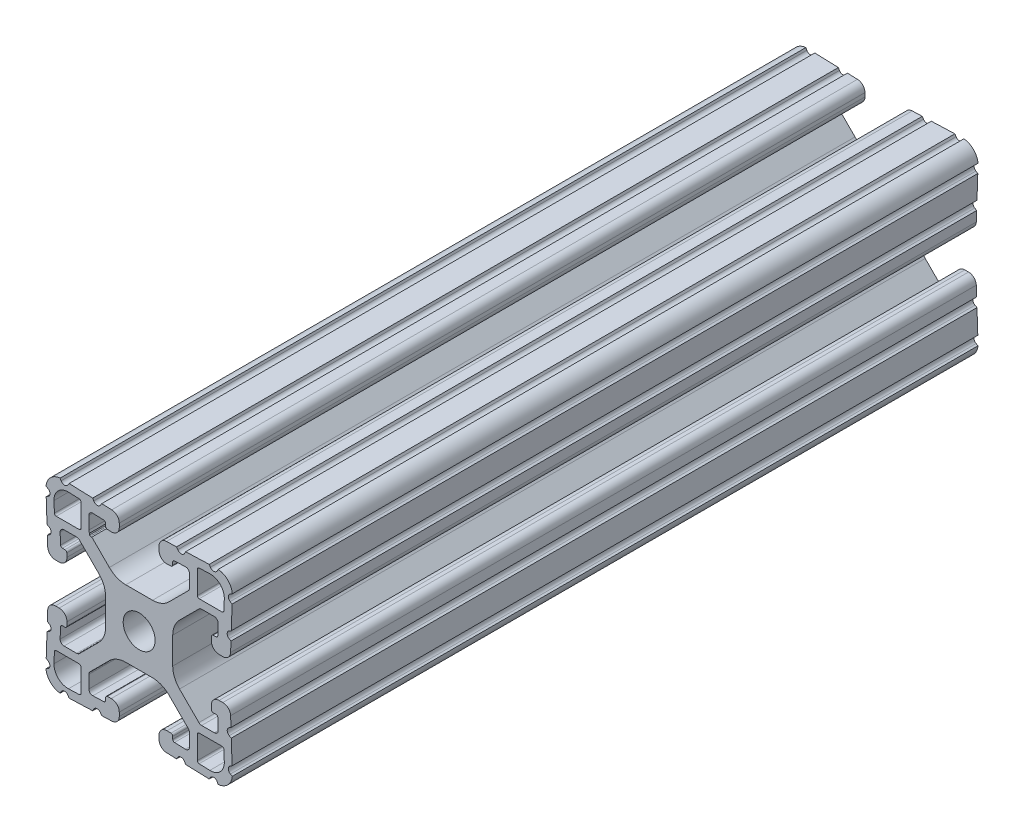
from build123d import *

# Parameters (mm, degrees)
BOSS_EXTRUDE1_DEPTH     = 76.2
CUT_EXTRUDE2_DEPTH      = 77.2
CUT_EXTRUDE2_DEPTH_BACK = 77.2
CUT_EXTRUDE1_DEPTH      = 77.2
CUT_EXTRUDE1_DEPTH_BACK = 77.2


with BuildPart() as part:
    # Sketch4 → Boss-Extrude1 (new body, symmetric)
    with BuildSketch(Plane.XY):
        with BuildLine():
            Line((15.764194098, -19.048065876), (5.596097049, -18.692988103))
            ThreePointArc((5.596097049, -18.692988103), (4.509548067, -18.209225328), (4.064, -17.106455165))
            Line((4.064, -17.106455165), (4.064, -16.343990692))
            ThreePointArc((4.064, -16.343990692), (4.548729837, -15.202038759), (5.706902951, -14.757457754))
            Line((5.706902951, -14.757457754), (6.490296708, -14.784814467))
            ThreePointArc((6.490296708, -14.784814467), (6.751068464, -14.900917533), (6.858, -15.165582372))
            Line((6.858, -15.165582372), (6.858, -15.689138401))
            ThreePointArc((6.858, -15.689138401), (6.964931536, -15.95380324), (7.225703292, -16.069906306))
            Line((7.225703292, -16.069906306), (9.465548524, -16.148123425))
            ThreePointArc((9.465548524, -16.148123425), (10.044635082, -15.925832923), (10.287, -15.354856956))
            Line((10.287, -15.354856956), (10.287, -12.771043484))
            ThreePointArc((10.287, -12.771043484), (10.226579379, -12.46728851), (10.054516008, -12.209777477))
            Line((10.054516008, -12.209777477), (6.093922742, -8.249184211))
            ThreePointArc((6.093922742, -8.249184211), (4.552976719, -7.219556996), (2.735306952, -6.858))
            Line((2.735306952, -6.858), (0, -6.858))
            Line((0, -6.858), (0, -3.2639))
            ThreePointArc((0, -3.2639), (2.307925823, -2.307925823), (3.2639, 0))
            Line((3.2639, 0), (6.858, 0))
            Line((6.858, 0), (6.858, -2.735306952))
            ThreePointArc((6.858, -2.735306952), (7.219556996, -4.552976719), (8.249184211, -6.093922742))
            Line((8.249184211, -6.093922742), (12.209777477, -10.054516008))
            ThreePointArc((12.209777477, -10.054516008), (12.46728851, -10.226579379), (12.771043484, -10.287))
            Line((12.771043484, -10.287), (15.354856956, -10.287))
            ThreePointArc((15.354856956, -10.287), (15.925832923, -10.044635082), (16.148123425, -9.465548524))
            Line((16.148123425, -9.465548524), (16.069906306, -7.225703292))
            ThreePointArc((16.069906306, -7.225703292), (15.95380324, -6.964931536), (15.689138401, -6.858))
            Line((15.689138401, -6.858), (15.165582372, -6.858))
            ThreePointArc((15.165582372, -6.858), (14.900917533, -6.751068464), (14.784814467, -6.490296708))
            Line((14.784814467, -6.490296708), (14.757457754, -5.706902951))
            ThreePointArc((14.757457754, -5.706902951), (15.202038759, -4.548729837), (16.343990692, -4.064))
            Line((16.343990692, -4.064), (17.106455165, -4.064))
            ThreePointArc((17.106455165, -4.064), (18.209225328, -4.509548067), (18.692988103, -5.596097049))
            Line((18.692988103, -5.596097049), (19.048065876, -15.764194098))
            ThreePointArc((19.048065876, -15.764194098), (18.12006403, -18.12006403), (15.764194098, -19.048065876))
        make_face()
        with BuildLine():
            Line((11.8872, -12.2682), (11.8872, -16.943575443))
            ThreePointArc((11.8872, -16.943575443), (11.994131536, -17.208240282), (12.254903292, -17.324343348))
            Line((12.254903292, -17.324343348), (14.445350862, -17.400835462))
            ThreePointArc((14.445350862, -17.400835462), (16.565633801, -16.565633801), (17.400835462, -14.445350862))
            Line((17.400835462, -14.445350862), (17.324343348, -12.254903292))
            ThreePointArc((17.324343348, -12.254903292), (17.208240282, -11.994131536), (16.943575443, -11.8872))
            Line((16.943575443, -11.8872), (12.2682, -11.8872))
            ThreePointArc((12.2682, -11.8872), (11.998792316, -11.998792316), (11.8872, -12.2682))
        make_face(mode=Mode.SUBTRACT)
    extrude(amount=BOSS_EXTRUDE1_DEPTH, both=True)

    # Sketch8 → Cut-Extrude2 (cut, two sides)
    with BuildSketch(Plane.XY) as cut_extrude2_sk:
        with BuildLine():
            Line((7.649186899, -18.76468358), (9.495813101, -18.829169188))
            Line((9.495813101, -18.829169188), (9.278946369, -18.421302187))
            ThreePointArc((9.278946369, -18.421302187), (8.600423087, -17.997313783), (7.893976718, -18.372937981))
            Line((7.893976718, -18.372937981), (7.649186899, -18.76468358))
        make_face()
        with BuildLine():
            Line((14.316686899, -18.997517811), (16.163313101, -19.062003418))
            Line((16.163313101, -19.062003418), (15.946446369, -18.654136417))
            ThreePointArc((15.946446369, -18.654136417), (15.267923087, -18.230148014), (14.561476718, -18.605772211))
            Line((14.561476718, -18.605772211), (14.316686899, -18.997517811))
        make_face()
        with BuildLine():
            Line((18.605772211, -14.561476718), (18.997517811, -14.316686899))
            Line((18.997517811, -14.316686899), (19.062003418, -16.163313101))
            Line((19.062003418, -16.163313101), (18.654136417, -15.946446369))
            ThreePointArc((18.654136417, -15.946446369), (18.230148014, -15.267923087), (18.605772211, -14.561476718))
        make_face()
        with BuildLine():
            Line((18.372937981, -7.893976718), (18.76468358, -7.649186899))
            Line((18.76468358, -7.649186899), (18.829169188, -9.495813101))
            Line((18.829169188, -9.495813101), (18.421302187, -9.278946369))
            ThreePointArc((18.421302187, -9.278946369), (17.997313783, -8.600423087), (18.372937981, -7.893976718))
        make_face()
    extrude(amount=CUT_EXTRUDE2_DEPTH, mode=Mode.SUBTRACT)
    extrude(cut_extrude2_sk.sketch, amount=-CUT_EXTRUDE2_DEPTH_BACK, mode=Mode.SUBTRACT)

    # Mirror1: part across plane


with BuildPart() as part_1:
    add(part.part)
    add(part.part.mirror(Plane(origin=(0, 0, 0), x_dir=(0, 0, 1), z_dir=(1, 0, 0))))

    # Mirror2: part across plane


with BuildPart() as part_2:
    add(part_1.part)
    add(part_1.part.mirror(Plane.ZX))

    # Sketch5 → Cut-Extrude1 (cut, two sides)
    with BuildSketch(Plane.XY) as cut_extrude1_sk:
        with BuildLine():
            Line((-10.133783723, 12.50797511), (-10.133783723, 11.99997511))
            ThreePointArc((-10.133783723, 11.99997511), (-10.084187138, 11.880238362), (-9.964450389, 11.830641777))
            Line((-9.964450389, 11.830641777), (-9.650582015, 11.830641777))
            Line((-9.650582015, 11.830641777), (-9.650582015, 12.50797511))
            Line((-9.650582015, 12.50797511), (-10.133783723, 12.50797511))
        make_face()
    extrude(amount=CUT_EXTRUDE1_DEPTH, mode=Mode.SUBTRACT)
    extrude(cut_extrude1_sk.sketch, amount=-CUT_EXTRUDE1_DEPTH_BACK, mode=Mode.SUBTRACT)


solid = part_2.part
